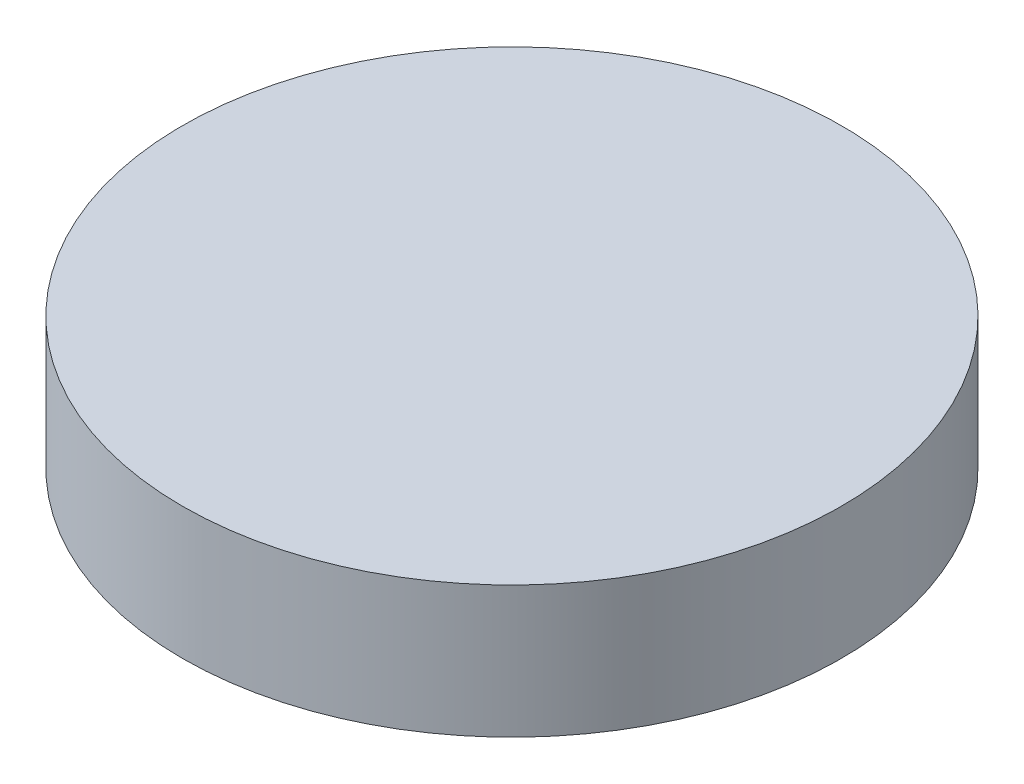
from build123d import *

# Parameters (mm, degrees)
SKETCH1_R           = 63.5
BOSS_EXTRUDE1_DEPTH = 25.4


with BuildPart() as part:
    # Sketch1 → Boss-Extrude1 (new body)
    with BuildSketch(Plane(origin=(0, 0, 0), x_dir=(1, 0, 0), z_dir=(0, 1, 0))):
        Circle(SKETCH1_R)
    extrude(amount=BOSS_EXTRUDE1_DEPTH)


solid = part.part
